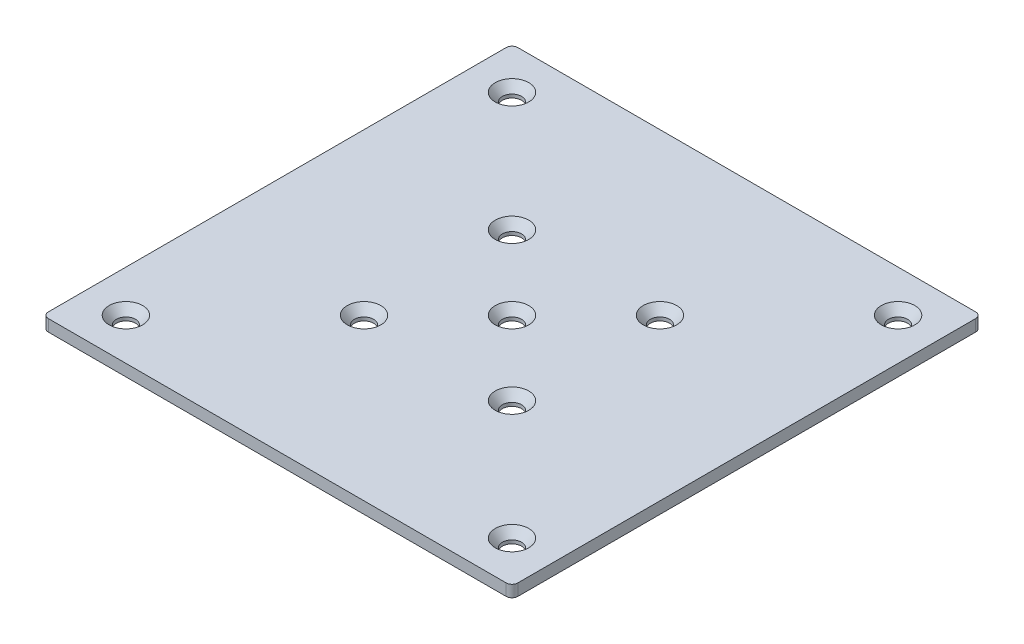
from build123d import *

# Parameters (mm, degrees)
ESQUISSE1_W                                  = 80
ESQUISSE1_H                                  = 80
BOSS_EXTRU_1_DEPTH                           = 2
FRAISAGE_POUR_VIS_T_TE_FRAIS_E_BOM_2_COUNT   = 2
FRAISAGE_POUR_VIS_T_TE_FRAIS_E_BOM_2_PITCH   = 65.794986025
FRAISAGE_POUR_VIS_T_TE_FRAIS_E_BOM_3_COUNT   = 2
FRAISAGE_POUR_VIS_T_TE_FRAIS_E_BOM_3_PITCH   = 93.048161572
FRAISAGE_POUR_VIS_T_TE_FRAIS_E_BOM_4_COUNT   = 2
FRAISAGE_POUR_VIS_T_TE_FRAIS_E_BOM_4_PITCH   = 65.794986025
FRAISAGE_POUR_VIS_T_TE_FRAIS_E_BOM_6_A_COUNT = 2
FRAISAGE_POUR_VIS_T_TE_FRAIS_E_BOM_6_A_PITCH = 25.212578074
FRAISAGE_POUR_VIS_T_TE_FRAIS_E_BOM_7_COUNT   = 2
FRAISAGE_POUR_VIS_T_TE_FRAIS_E_BOM_7_PITCH   = 35.655969855
FRAISAGE_POUR_VIS_T_TE_FRAIS_E_BOM_8_COUNT   = 2
FRAISAGE_POUR_VIS_T_TE_FRAIS_E_BOM_8_PITCH   = 25.212578074
CONG_1_R                                     = 1
CONG_2_R                                     = 1


with BuildPart() as part:
    # Esquisse1 → Boss.-Extru.1 (new body)
    with BuildSketch(Plane(origin=(0, 0, 0), x_dir=(1, 0, 0), z_dir=(0, 1, 0))):
        Rectangle(ESQUISSE1_W, ESQUISSE1_H)
    extrude(amount=BOSS_EXTRU_1_DEPTH)

    # Esquisse3 → Fraisage pour vis _ t_te frais_e bomb_e (revolve, cut)
    with BuildSketch(Plane(origin=(-32.897493012, 2, -32.897493012), x_dir=(0, 0, 1), z_dir=(1, 0, 0))):
        Polygon((0, 0), (0, 2), (1.63195, 2), (1.63195, 1.409834001), (2.8575, 0), align=None)
    fraisage_pour_vis_t_te_frais_e_bomb_e = revolve(axis=Axis((-32.897493012, 8.35, -32.897493012), (0, -1, 0)), mode=Mode.SUBTRACT)

    # Fraisage pour vis _ t_te frais_e bom 2: Fraisage pour vis _ t_te frais_e bomb_e ×2
    with Locations(*[(i * FRAISAGE_POUR_VIS_T_TE_FRAIS_E_BOM_2_PITCH, 0, 0) for i in range(1, FRAISAGE_POUR_VIS_T_TE_FRAIS_E_BOM_2_COUNT)]):
        add(fraisage_pour_vis_t_te_frais_e_bomb_e, mode=Mode.SUBTRACT)

    # Fraisage pour vis _ t_te frais_e bom 3: Fraisage pour vis _ t_te frais_e bomb_e ×2
    with Locations(*[Vector(0.707106781, 0, 0.707106781) * (i * FRAISAGE_POUR_VIS_T_TE_FRAIS_E_BOM_3_PITCH) for i in range(1, FRAISAGE_POUR_VIS_T_TE_FRAIS_E_BOM_3_COUNT)]):
        add(fraisage_pour_vis_t_te_frais_e_bomb_e, mode=Mode.SUBTRACT)

    # Fraisage pour vis _ t_te frais_e bom 4: Fraisage pour vis _ t_te frais_e bomb_e ×2
    with Locations(*[(0, 0, i * FRAISAGE_POUR_VIS_T_TE_FRAIS_E_BOM_4_PITCH) for i in range(1, FRAISAGE_POUR_VIS_T_TE_FRAIS_E_BOM_4_COUNT)]):
        add(fraisage_pour_vis_t_te_frais_e_bomb_e, mode=Mode.SUBTRACT)

    # Esquisse6 → Fraisage pour vis _ t_te frais_e bom 5 (revolve, cut)
    with BuildSketch(Plane(origin=(0, 2, 0), x_dir=(0, 0, 1), z_dir=(1, 0, 0))):
        Polygon((0, 0), (0, 2), (1.63195, 2), (1.63195, 1.409834001), (2.8575, 0), align=None)
    revolve(axis=Axis((0, 8.35, 0), (0, -1, 0)), mode=Mode.SUBTRACT)

    # Esquisse8 → Fraisage pour vis _ t_te frais_e bom 6 (revolve, cut)
    with BuildSketch(Plane(origin=(-12.606289037, 2, -12.606289037), x_dir=(0, 0, 1), z_dir=(1, 0, 0))):
        Polygon((0, 0), (0, 2), (1.63195, 2), (1.63195, 1.409834001), (2.8575, 0), align=None)
    fraisage_pour_vis_t_te_frais_e_bom_6 = revolve(axis=Axis((-12.606289037, 8.35, -12.606289037), (0, -1, 0)), mode=Mode.SUBTRACT)

    # Fraisage pour vis _ t_te frais_e bom 6 a: Fraisage pour vis _ t_te frais_e bom 6 ×2
    with Locations(*[(i * FRAISAGE_POUR_VIS_T_TE_FRAIS_E_BOM_6_A_PITCH, 0, 0) for i in range(1, FRAISAGE_POUR_VIS_T_TE_FRAIS_E_BOM_6_A_COUNT)]):
        add(fraisage_pour_vis_t_te_frais_e_bom_6, mode=Mode.SUBTRACT)

    # Fraisage pour vis _ t_te frais_e bom 7: Fraisage pour vis _ t_te frais_e bom 6 ×2
    with Locations(*[Vector(0.707106781, 0, 0.707106781) * (i * FRAISAGE_POUR_VIS_T_TE_FRAIS_E_BOM_7_PITCH) for i in range(1, FRAISAGE_POUR_VIS_T_TE_FRAIS_E_BOM_7_COUNT)]):
        add(fraisage_pour_vis_t_te_frais_e_bom_6, mode=Mode.SUBTRACT)

    # Fraisage pour vis _ t_te frais_e bom 8: Fraisage pour vis _ t_te frais_e bom 6 ×2
    with Locations(*[(0, 0, i * FRAISAGE_POUR_VIS_T_TE_FRAIS_E_BOM_8_PITCH) for i in range(1, FRAISAGE_POUR_VIS_T_TE_FRAIS_E_BOM_8_COUNT)]):
        add(fraisage_pour_vis_t_te_frais_e_bom_6, mode=Mode.SUBTRACT)

    # Congé1
    cong_1_edges = [part.edges().sort_by_distance(p)[0] for p in [
        (-40, 1, 40),
    ]]
    fillet(cong_1_edges, radius=CONG_1_R)

    # Congé2
    cong_2_edges = [part.edges().sort_by_distance(p)[0] for p in [
        (40, 1, 40),
        (-40, 1, -40),
        (40, 1, -40),
    ]]
    fillet(cong_2_edges, radius=CONG_2_R)


solid = part.part
